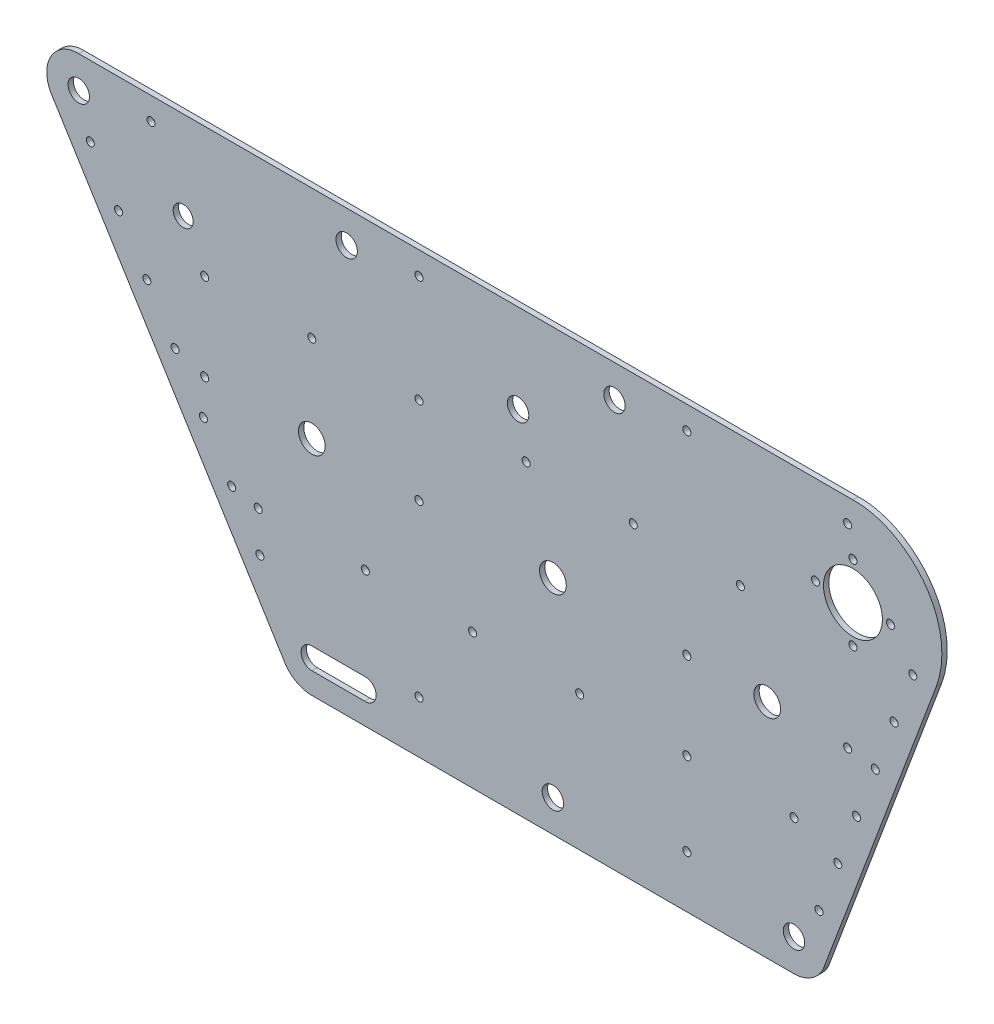
from build123d import *

# Parameters (mm, degrees)
BOSS_EXTRUDE1_DEPTH = 2
SKETCH4_R           = 3.9998
SKETCH4_R_2         = 1.499925
SKETCH4_R_3         = 3.7498125
SKETCH4_R_4         = 10.99945
SKETCH4_R_5         = 4.99975
SKETCH4_R_6         = 3.999800521
CUT_EXTRUDE1_DEPTH  = 2


with BuildPart() as part:
    # Sketch3 → Boss-Extrude1 (new body)
    with BuildSketch(Plane.XY):
        with BuildLine():
            Line((-106.00519968, 144.943614194), (182.96308424, 145.197672799))
            add(Edge.make_bspline(
                [(214.06903129, 100.332253713), (217.202846332, 108.581551057), (216.384279944, 131.51380425), (195.382789786, 145.608716116), (182.96308424, 145.197672799)],
                knots=[0, 0, 0, 0, 0.416238876, 1, 1, 1, 1], degree=3))
            Line((214.06903129, 100.332253713), (171.900116679, -12))
            add(Edge.make_bspline(
                [(160.991950179, -19), (165.457889658, -19.068752161), (170.106996065, -16.09051608), (171.900116679, -12)],
                knots=[0, 0, 0, 0, 1, 1, 1, 1], degree=3))
            Line((160.991950179, -19), (-18.999049973, -19))
            add(Edge.make_bspline(
                [(-18.999049973, -19), (-23.419302443, -19.069581379), (-27.756029743, -16.362926839), (-29.701931061, -12.425576557)],
                knots=[0, 0, 0, 0, 1, 1, 1, 1], degree=3))
            Line((-29.701931061, -12.425576557), (-116.08546313, 126.611232779))
            add(Edge.make_bspline(
                [(-106.00519968, 144.943614194), (-112.924010598, 145.092654371), (-119.661868892, 137.031763828), (-117.348474018, 128.592298794), (-116.08546313, 126.611232779)],
                knots=[0, 0, 0, 0, 0.715346285, 1, 1, 1, 1], degree=3))
        make_face()
    extrude(amount=BOSS_EXTRUDE1_DEPTH)

    # Sketch4 → Cut-Extrude1 (cut)
    with BuildSketch(Plane.XY.offset(2)):
        with Locations((-105.9947, 133)):
            Circle(SKETCH4_R)
        with Locations((-78.996040132, 136.5)):
            Circle(SKETCH4_R_2)
        with Locations((-101.689209002, 118.598380963)):
            Circle(SKETCH4_R_2)
        with Locations((-91.134705429, 101.610600241)):
            Circle(SKETCH4_R_2)
        with Locations((-66.99665, 112)):
            Circle(SKETCH4_R_3)
        with Locations((-80.580283096, 84.622950275)):
            Circle(SKETCH4_R_2)
        with Locations((-5.9997, 133)):
            Circle(SKETCH4_R)
        with Locations((20.99895, 136.5)):
            Circle(SKETCH4_R_2)
        with Locations((20.99895, 96.5)):
            Circle(SKETCH4_R_2)
        with Locations((-18.99905, 96.5)):
            Circle(SKETCH4_R_2)
        with Locations((-58.99705, 96.5)):
            Circle(SKETCH4_R_2)
        with Locations((57.9971, 112)):
            Circle(SKETCH4_R)
        with Locations((60.99695, 96.5)):
            Circle(SKETCH4_R_2)
        with Locations((182.99085, 112)):
            Circle(SKETCH4_R_4)
        with Locations((182.99085, 126)):
            Circle(SKETCH4_R_2)
        with Locations((180.99095, 136.5)):
            Circle(SKETCH4_R_2)
        with Locations((120.99395, 136.5)):
            Circle(SKETCH4_R_2)
        with Locations((93.995220809, 133)):
            Circle(SKETCH4_R)
        with Locations((100.99495, 96.5)):
            Circle(SKETCH4_R_2)
        with Locations((140.99295, 96.5)):
            Circle(SKETCH4_R_2)
        with Locations((168.99155, 112)):
            Circle(SKETCH4_R_2)
        with Locations((196.99015, 112)):
            Circle(SKETCH4_R_2)
        with Locations((182.99085, 98)):
            Circle(SKETCH4_R_2)
        with Locations((205.322481122, 99.795751553)):
            Circle(SKETCH4_R_2)
        with Locations((198.324441471, 81.060193672)):
            Circle(SKETCH4_R_2)
        with Locations((150.99245, 64)):
            Circle(SKETCH4_R_5)
        with Locations((180.99095, 64)):
            Circle(SKETCH4_R_2)
        with Locations((191.32646769, 62.324812144)):
            Circle(SKETCH4_R_2)
        with Locations((120.99395, 64)):
            Circle(SKETCH4_R_2)
        with Locations((184.328557385, 43.589600555)):
            Circle(SKETCH4_R_2)
        with Locations((70.99645, 64)):
            Circle(SKETCH4_R_5)
        with Locations((20.99895, 64)):
            Circle(SKETCH4_R_2)
        with Locations((0.99995, 31.499992415)):
            Circle(SKETCH4_R_2)
        with Locations((40.99795, 31.499988622)):
            Circle(SKETCH4_R_2)
        with Locations((80.99595, 31.499985778)):
            Circle(SKETCH4_R_2)
        with Locations((120.99395, 31.499981037)):
            Circle(SKETCH4_R_2)
        with Locations((160.99195, 31.499978192)):
            Circle(SKETCH4_R_2)
        with Locations((177.330672341, 24.854456596)):
            Circle(SKETCH4_R_2)
        with Locations((-18.99905, 64)):
            Circle(SKETCH4_R_5)
        with Locations((-70.02547384, 67.634677545)):
            Circle(SKETCH4_R_2)
        with Locations((-58.99705, 64)):
            Circle(SKETCH4_R_2)
        with Locations((-59.470762984, 50.646563195)):
            Circle(SKETCH4_R_2)
        with Locations((-48.916261932, 33.658786529)):
            Circle(SKETCH4_R_2)
        with Locations((-38.99805, 31.499994311)):
            Circle(SKETCH4_R_2)
        with Locations((-38.361920415, 16.671266638)):
            Circle(SKETCH4_R_2)
        with Locations((20.99895, 0.5)):
            Circle(SKETCH4_R_2)
        with Locations((70.99645, -7)):
            Circle(SKETCH4_R_6)
        with Locations((160.99195, -7)):
            Circle(SKETCH4_R)
        with Locations((170.332531489, 6.118627774)):
            Circle(SKETCH4_R_2)
        with Locations((120.99395, 0.5)):
            Circle(SKETCH4_R_2)
        with BuildLine():
            Line((-18.99905, -3), (0.99995, -3))
            ThreePointArc((0.99995, -3), (4.997795472, -7.128933101), (0.749772406, -11))
            Line((0.749772406, -11), (-18.99905, -11))
            ThreePointArc((-18.99905, -11), (-22.99885, -7), (-18.99905, -3))
        make_face()
    extrude(amount=-CUT_EXTRUDE1_DEPTH, mode=Mode.SUBTRACT)


solid = part.part
